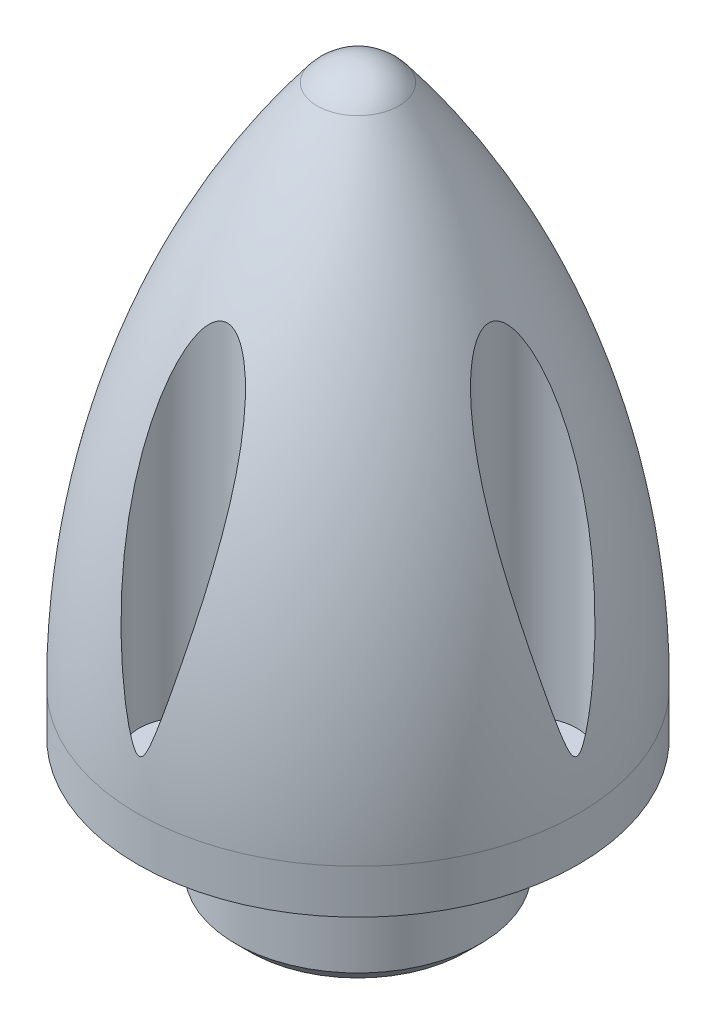
from build123d import *

# Parameters (mm, degrees)
SKETCH3_R           = 3.81
CUT_EXTRUDE1_DEPTH  = 58.501695693
SKETCH5_R           = 10.593705
SKETCH5_R_2         = 8.763
BOSS_EXTRUDE7_DEPTH = 17.78
SKETCH3_4_R         = 3.81
SKETCH3_4_R_2       = 1.62052
BOSS_EXTRUDE8_DEPTH = 6.35
CHAMFER1_SIZE       = 1.27


with BuildPart() as part:
    # Sketch2 → Revolve1 (revolve)
    with BuildSketch(Plane(origin=(0, 0, 0), x_dir=(0, 0, -1), z_dir=(1, 0, 0))):
        with BuildLine():
            Line((0, 50.8), (0, 47.192501809))
            ThreePointArc((0, 47.192501809), (7.113867191, 24.099005122), (8.89, 0))
            Line((8.89, 0), (19.05, 0))
            Line((19.05, 0), (19.05, 3.81))
            ThreePointArc((19.05, 3.81), (15.061820516, 27.735389015), (3.528565936, 49.073473604))
            ThreePointArc((3.528565936, 49.073473604), (1.964158278, 50.345229375), (0, 50.8))
        make_face()
    revolve(axis=Axis((0, 0, 0), (0, 1, 0)))

    # Sketch3 → Cut-Extrude1 (cut, through all)
    with BuildSketch(Plane.XZ):
        with Locations((15.11808, 0)):
            Circle(SKETCH3_R)
        with Locations((0, -15.11808)):
            Circle(SKETCH3_R)
        with Locations((-15.11808, 0)):
            Circle(SKETCH3_R)
        with Locations((0, 15.11808)):
            Circle(SKETCH3_R)
    extrude(amount=-CUT_EXTRUDE1_DEPTH, mode=Mode.SUBTRACT)

    # Sketch5 → Boss-Extrude7 (add)
    with BuildSketch(Plane(origin=(0, 6.35, 0), x_dir=(-1, 0, 0), z_dir=(0, -1, 0))):
        Circle(SKETCH5_R)
        Circle(SKETCH5_R_2, mode=Mode.SUBTRACT)
    extrude(amount=BOSS_EXTRUDE7_DEPTH)

    # Sketch3_4 → Boss-Extrude8 (add)
    # profile 1 of 4: a face of its own
    with BuildSketch(Plane.XZ):
        with Locations((15.11808, 0)):
            Circle(SKETCH3_4_R)
        with Locations((15.11808, 0)):
            Circle(SKETCH3_4_R_2, mode=Mode.SUBTRACT)
    # profile 2 of 4: a face of its own
    with BuildSketch(Plane.XZ):
        with Locations((0, -15.11808)):
            Circle(SKETCH3_4_R)
        with Locations((0, -15.11808)):
            Circle(SKETCH3_4_R_2, mode=Mode.SUBTRACT)
    # profile 3 of 4: a face of its own
    with BuildSketch(Plane.XZ):
        with Locations((-15.11808, 0)):
            Circle(SKETCH3_4_R)
        with Locations((-15.11808, 0)):
            Circle(SKETCH3_4_R_2, mode=Mode.SUBTRACT)
    # profile 4 of 4: a face of its own
    with BuildSketch(Plane.XZ):
        with Locations((0, 15.11808)):
            Circle(SKETCH3_4_R)
        with Locations((0, 15.11808)):
            Circle(SKETCH3_4_R_2, mode=Mode.SUBTRACT)
    extrude(amount=-BOSS_EXTRUDE8_DEPTH)

    # Chamfer1
    chamfer1_edges = [part.edges().sort_by_distance(p)[0] for p in [
        (10.593705, -11.43, 0),
    ]]
    chamfer(chamfer1_edges, length=CHAMFER1_SIZE)


solid = part.part
